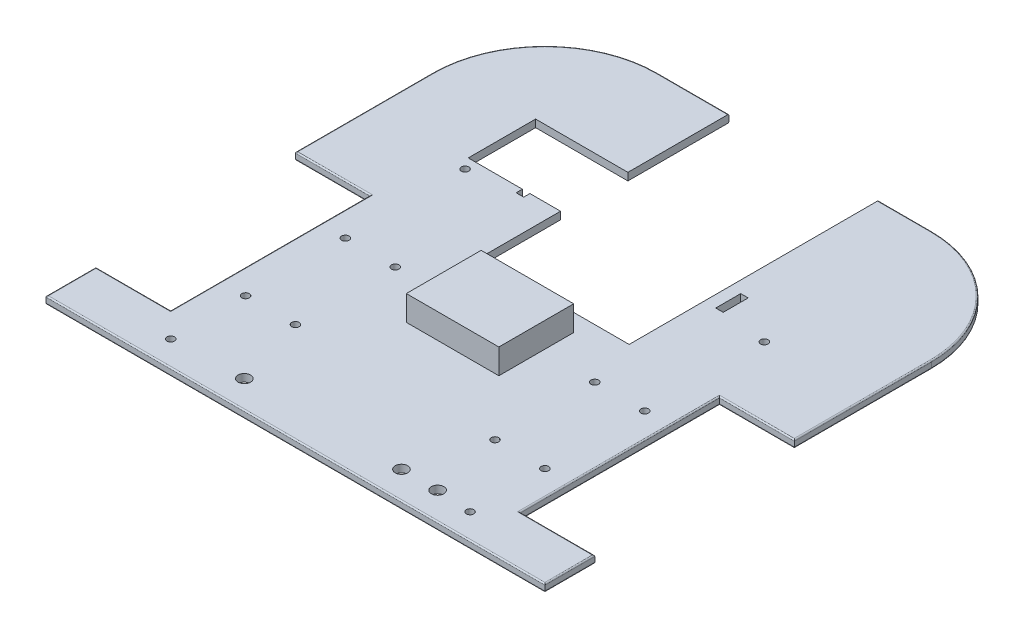
from build123d import *

# Parameters (mm, degrees)
SKETCH1_W               = 200
SKETCH1_H               = 200
BOSS_EXTRUDE1_DEPTH     = 3
CUT_EXTRUDE1_START      = -142.453172464
SKETCH2_W               = 30
SKETCH2_H               = 80
CUT_EXTRUDE1_DEPTH      = 152.453172464
FILLET1_R               = 45
SKETCH10_R              = 1.5
CUT_EXTRUDE9_DEPTH      = 142.453172464
LPATTERN1_COUNT         = 2
LPATTERN1_PITCH         = 40
LPATTERN1_COUNT_DIR2    = 2
LPATTERN1_PITCH_DIR2    = 20
SKETCH13_R              = 1.5
SKETCH13_W              = 3
SKETCH13_H              = 10
CUT_EXTRUDE10_DEPTH     = 142.453172464
SKETCH14_R              = 1.5
CUT_EXTRUDE11_DEPTH     = 142.453172464
MIRROR1_COPY_1_SKETCH_R = 1.5
MIRROR1_COPY_1_DEPTH    = 142.453172464
MIRROR1_COPY_2_SKETCH_R = 1.5
MIRROR1_COPY_2_DEPTH    = 142.453172464
MIRROR1_COPY_3_SKETCH_R = 1.5
MIRROR1_COPY_3_DEPTH    = 142.453172464
FILLET2_R               = 0.5
SKETCH23_W              = 60
SKETCH23_H              = 70
CUT_EXTRUDE13_DEPTH     = 10
SKETCH25_W              = 60
SKETCH25_H              = 33
CUT_EXTRUDE15_DEPTH     = 10
SKETCH26_W              = 37.10221973
SKETCH26_H              = 30
BOSS_EXTRUDE3_DEPTH     = 10
SKETCH27_W              = 37
SKETCH27_H              = 27
CUT_EXTRUDE16_DEPTH     = 10
SKETCH30_R              = 2.5
CUT_EXTRUDE17_DEPTH     = 10
SKETCH31_R              = 2.5
CUT_EXTRUDE18_DEPTH     = 10


with BuildPart() as part:
    # Sketch1 → Boss-Extrude1 (new body)
    with BuildSketch(Plane(origin=(0, 0, 0), x_dir=(1, 0, 0), z_dir=(0, 1, 0))):
        Rectangle(SKETCH1_W, SKETCH1_H)
    extrude(amount=BOSS_EXTRUDE1_DEPTH)

    # Sketch2 → Cut-Extrude1 (cut)
    with BuildSketch(Plane(origin=(0, 3, 0), x_dir=(1, 0, 0), z_dir=(0, 1, 0)).offset(CUT_EXTRUDE1_START)):
        with Locations((-85, -40)):
            Rectangle(SKETCH2_W, SKETCH2_H)
    cut_extrude1 = extrude(amount=CUT_EXTRUDE1_DEPTH, mode=Mode.SUBTRACT)

    # Fillet1
    fillet1_edges = [part.edges().sort_by_distance(p)[0] for p in [
        (100, 1.5, -100),
        (-100, 1.5, -100),
    ]]
    fillet(fillet1_edges, radius=FILLET1_R)

    # Sketch10 → Cut-Extrude9 (cut, through all)
    with BuildSketch(Plane(origin=(0, 3, 0), x_dir=(1, 0, 0), z_dir=(0, 1, 0))):
        with Locations((-60, -60)):
            Circle(SKETCH10_R)
    cut_extrude9 = extrude(amount=-CUT_EXTRUDE9_DEPTH, mode=Mode.SUBTRACT)

    # LPattern1: Cut-Extrude9 2 × 2
    with Locations(*[(j * LPATTERN1_PITCH_DIR2, 0, -i * LPATTERN1_PITCH) for i in range(LPATTERN1_COUNT) for j in range(LPATTERN1_COUNT_DIR2) if (i, j) != (0, 0)]):
        add(cut_extrude9, mode=Mode.SUBTRACT)

    # Sketch13 → Cut-Extrude10 (cut, through all)
    with BuildSketch(Plane(origin=(0, 3, 0), x_dir=(1, 0, 0), z_dir=(0, 1, 0))):
        with Locations((-60, 28)):
            Circle(SKETCH13_R)
        with Locations((-40, 35)):
            Rectangle(SKETCH13_W, SKETCH13_H)
    cut_extrude10 = extrude(amount=-CUT_EXTRUDE10_DEPTH, mode=Mode.SUBTRACT)

    # Sketch14 → Cut-Extrude11 (cut, through all)
    with BuildSketch(Plane(origin=(0, 3, 0), x_dir=(1, 0, 0), z_dir=(0, 1, 0))):
        with Locations((-60, -90)):
            Circle(SKETCH14_R)
    cut_extrude11 = extrude(amount=-CUT_EXTRUDE11_DEPTH, mode=Mode.SUBTRACT)

    # Mirror1: Cut-Extrude1, Cut-Extrude9, Cut-Extrude10, Cut-Extrude11 across plane
    add(cut_extrude1.mirror(Plane(origin=(0, 0, 0), x_dir=(0, 0, 1), z_dir=(1, 0, 0))), mode=Mode.SUBTRACT)
    add(cut_extrude9.mirror(Plane(origin=(0, 0, 0), x_dir=(0, 0, 1), z_dir=(1, 0, 0))), mode=Mode.SUBTRACT)
    add(cut_extrude10.mirror(Plane(origin=(0, 0, 0), x_dir=(0, 0, 1), z_dir=(1, 0, 0))), mode=Mode.SUBTRACT)
    add(cut_extrude11.mirror(Plane(origin=(0, 0, 0), x_dir=(0, 0, 1), z_dir=(1, 0, 0))), mode=Mode.SUBTRACT)

    # Mirror1 copy 1 sketch → Mirror1 copy 1 (cut, through all)
    with BuildSketch(Plane(origin=(-20, 3, 0), x_dir=(-1, 0, 0), z_dir=(0, 1, 0))):
        with Locations((-60, 60)):
            Circle(MIRROR1_COPY_1_SKETCH_R)
    extrude(amount=-MIRROR1_COPY_1_DEPTH, mode=Mode.SUBTRACT)

    # Mirror1 copy 2 sketch → Mirror1 copy 2 (cut, through all)
    with BuildSketch(Plane(origin=(0, 3, -40), x_dir=(-1, 0, 0), z_dir=(0, 1, 0))):
        with Locations((-60, 60)):
            Circle(MIRROR1_COPY_2_SKETCH_R)
    extrude(amount=-MIRROR1_COPY_2_DEPTH, mode=Mode.SUBTRACT)

    # Mirror1 copy 3 sketch → Mirror1 copy 3 (cut, through all)
    with BuildSketch(Plane(origin=(-20, 3, -40), x_dir=(-1, 0, 0), z_dir=(0, 1, 0))):
        with Locations((-60, 60)):
            Circle(MIRROR1_COPY_3_SKETCH_R)
    extrude(amount=-MIRROR1_COPY_3_DEPTH, mode=Mode.SUBTRACT)

    # Fillet2
    fillet2_edges = [part.edges().sort_by_distance(p)[0] for p in [
        (100, 3, -27.5),
        (86.819805153, 3, -86.819805153),
        (-100, 3, -27.5),
        (-86.819805153, 3, -86.819805153),
        (100, 0, 90),
        (85, 0, 80),
        (70, 0, 40),
        (85, 0, 0),
        (100, 0, -27.5),
        (86.819805153, 0, -86.819805153),
        (0, 0, -100),
        (-100, 0, -27.5),
        (-86.819805153, 0, -86.819805153),
        (-85, 0, 0),
        (-70, 0, 40),
        (-85, 0, 80),
        (-100, 0, 90),
        (0, 0, 100),
        (-85, 3, 80),
        (-100, 3, 90),
        (0, 3, 100),
        (100, 3, 90),
        (85, 3, 80),
        (70, 3, 40),
        (85, 3, 0),
        (-85, 3, 0),
        (-70, 3, 40),
        (0, 3, -100),
    ]]
    fillet(fillet2_edges, radius=FILLET2_R)

    # Sketch23 → Cut-Extrude13 (cut)
    with BuildSketch(Plane(origin=(0, 3, 0), x_dir=(1, 0, 0), z_dir=(0, 1, 0))):
        with Locations((3.779632889, 35)):
            Rectangle(SKETCH23_W, SKETCH23_H)
    extrude(amount=-CUT_EXTRUDE13_DEPTH, mode=Mode.SUBTRACT)

    # Sketch25 → Cut-Extrude15 (cut)
    with BuildSketch(Plane(origin=(0, 3, 0), x_dir=(1, 0, 0), z_dir=(0, 1, 0))):
        with Locations((3.779632889, 86.5)):
            Rectangle(SKETCH25_W, SKETCH25_H)
    extrude(amount=-CUT_EXTRUDE15_DEPTH, mode=Mode.SUBTRACT)

    # Sketch26 → Boss-Extrude3 (add)
    with BuildSketch(Plane(origin=(0, 3, 0), x_dir=(1, 0, 0), z_dir=(0, 1, 0))):
        with Locations((0, -22)):
            Rectangle(SKETCH26_W, SKETCH26_H)
    extrude(amount=BOSS_EXTRUDE3_DEPTH)

    # Sketch27 → Cut-Extrude16 (cut)
    with BuildSketch(Plane(origin=(0, 3, 0), x_dir=(1, 0, 0), z_dir=(0, 1, 0))):
        with Locations((-44.720367111, 46)):
            Rectangle(SKETCH27_W, SKETCH27_H)
    extrude(amount=-CUT_EXTRUDE16_DEPTH, mode=Mode.SUBTRACT)

    # Sketch30 → Cut-Extrude17 (cut)
    with BuildSketch(Plane(origin=(0, 3, 0), x_dir=(1, 0, 0), z_dir=(0, 1, 0))):
        with Locations((-31.5, -89)):
            Circle(SKETCH30_R)
        with Locations((31.5, -89)):
            Circle(SKETCH30_R)
    extrude(amount=-CUT_EXTRUDE17_DEPTH, mode=Mode.SUBTRACT)

    # Sketch31 → Cut-Extrude18 (cut)
    with BuildSketch(Plane(origin=(0, 3, 0), x_dir=(1, 0, 0), z_dir=(0, 1, 0))):
        with Locations((46, -89)):
            Circle(SKETCH31_R)
    extrude(amount=-CUT_EXTRUDE18_DEPTH, mode=Mode.SUBTRACT)


solid = part.part
